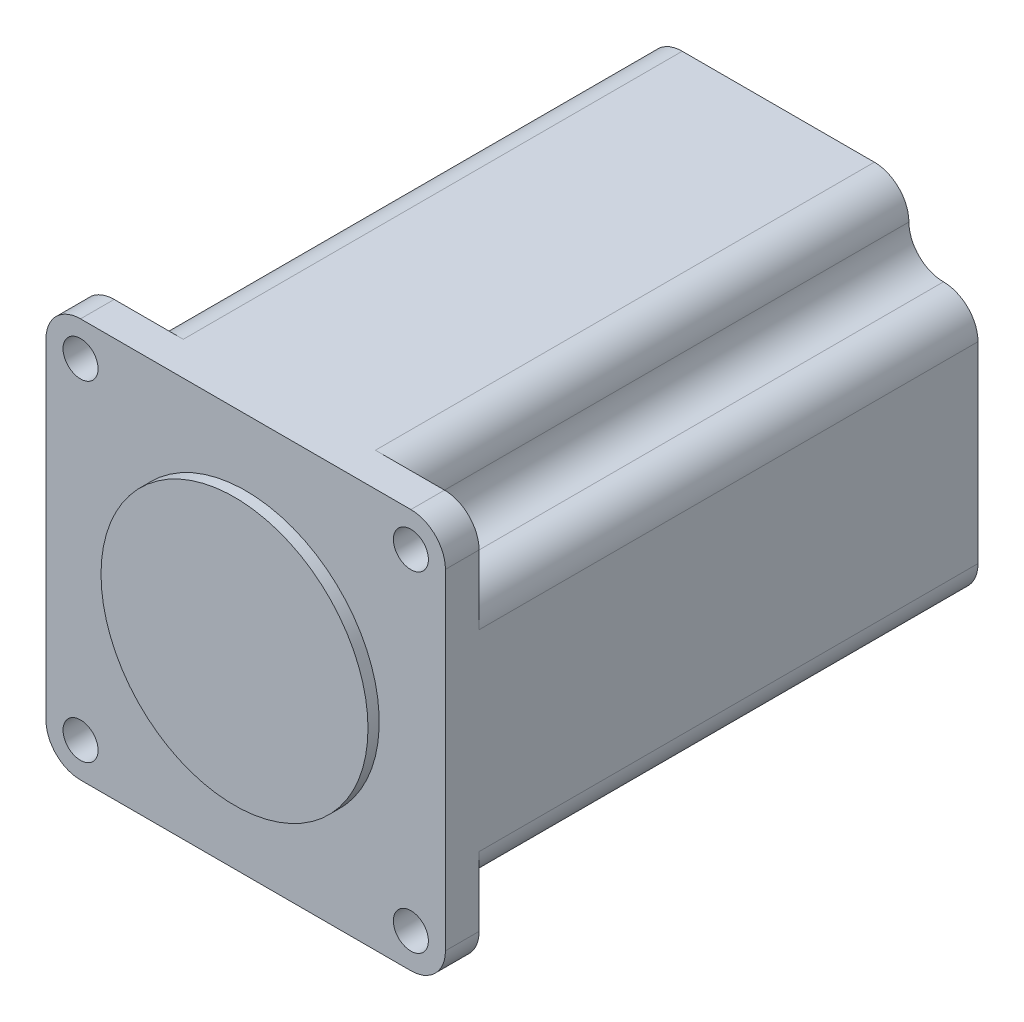
from build123d import *

# Parameters (mm, degrees)
SKETCH1_W           = 57
SKETCH1_H           = 57
BOSS_EXTRUDE1_DEPTH = 76
SKETCH3_R           = 2.5
CUT_EXTRUDE1_DEPTH  = 77
CUT_EXTRUDE2_DEPTH  = 77
SKETCH5_OUTSIDE_W   = 81.158
SKETCH5_OUTSIDE_H   = 81.158
CUT_EXTRUDE3_DEPTH  = 71.2
SKETCH6_R           = 19.05
BOSS_EXTRUDE2_DEPTH = 1.6


with BuildPart() as part:
    # Sketch1 → Boss-Extrude1 (new body)
    with BuildSketch(Plane.XY):
        Rectangle(SKETCH1_W, SKETCH1_H)
    extrude(amount=-BOSS_EXTRUDE1_DEPTH)

    # Sketch3 → Cut-Extrude1 (cut, through all)
    with BuildSketch(Plane(origin=(0, 0, -76), x_dir=(-1, 0, 0), z_dir=(0, 0, -1))):
        with Locations((-23.57, 23.57)):
            Circle(SKETCH3_R)
        with Locations((-23.57, -23.57)):
            Circle(SKETCH3_R)
        with Locations((23.57, 23.57)):
            Circle(SKETCH3_R)
        with Locations((23.57, -23.57)):
            Circle(SKETCH3_R)
    extrude(amount=-CUT_EXTRUDE1_DEPTH, mode=Mode.SUBTRACT)

    # Sketch4 → Cut-Extrude2 (cut, through all)
    with BuildSketch(Plane(origin=(0, 0, -76), x_dir=(-1, 0, 0), z_dir=(0, 0, -1))):
        with BuildLine():
            Line((-28.5, 23.57), (-28.5, 28.5))
            Line((-28.5, 28.5), (-23.57, 28.5))
            ThreePointArc((-23.57, 28.5), (-27.056036431, 27.056036431), (-28.5, 23.57))
        make_face()
        with BuildLine():
            Line((23.57, 28.5), (28.5, 28.5))
            Line((28.5, 28.5), (28.5, 23.57))
            ThreePointArc((28.5, 23.57), (27.056036431, 27.056036431), (23.57, 28.5))
        make_face()
        with BuildLine():
            Line((-28.5, -23.57), (-28.5, -28.5))
            Line((-28.5, -28.5), (-23.57, -28.5))
            ThreePointArc((-23.57, -28.5), (-27.056036431, -27.056036431), (-28.5, -23.57))
        make_face()
        with BuildLine():
            Line((23.57, -28.5), (28.5, -28.5))
            Line((28.5, -28.5), (28.5, -23.57))
            ThreePointArc((28.5, -23.57), (27.056036431, -27.056036431), (23.57, -28.5))
        make_face()
    extrude(amount=-CUT_EXTRUDE2_DEPTH, mode=Mode.SUBTRACT)

    # Sketch5 outside → Cut-Extrude3 (cut)
    with BuildSketch(Plane(origin=(0, 0, -76), x_dir=(-1, 0, 0), z_dir=(0, 0, -1))):
        Rectangle(SKETCH5_OUTSIDE_W, SKETCH5_OUTSIDE_H)
        with BuildLine():
            Line((-28.5, 13.71), (-28.5, -13.71))
            ThreePointArc((-28.5, -13.71), (-27.056036431, -17.196036431), (-23.57, -18.64))
            ThreePointArc((-23.57, -18.64), (-20.083963569, -20.083963569), (-18.64, -23.57))
            ThreePointArc((-18.64, -23.57), (-17.196036431, -27.056036431), (-13.71, -28.5))
            Line((-13.71, -28.5), (13.71, -28.5))
            ThreePointArc((13.71, -28.5), (17.196036431, -27.056036431), (18.64, -23.57))
            ThreePointArc((18.64, -23.57), (20.083963569, -20.083963569), (23.57, -18.64))
            ThreePointArc((23.57, -18.64), (27.056036431, -17.196036431), (28.5, -13.71))
            Line((28.5, -13.71), (28.5, 13.71))
            ThreePointArc((28.5, 13.71), (27.056036431, 17.196036431), (23.57, 18.64))
            ThreePointArc((23.57, 18.64), (20.083963569, 20.083963569), (18.64, 23.57))
            ThreePointArc((18.64, 23.57), (17.196036431, 27.056036431), (13.71, 28.5))
            Line((13.71, 28.5), (-13.71, 28.5))
            ThreePointArc((-13.71, 28.5), (-17.196036431, 27.056036431), (-18.64, 23.57))
            ThreePointArc((-18.64, 23.57), (-20.083963569, 20.083963569), (-23.57, 18.64))
            ThreePointArc((-23.57, 18.64), (-27.056036431, 17.196036431), (-28.5, 13.71))
        make_face(mode=Mode.SUBTRACT)
    extrude(amount=-CUT_EXTRUDE3_DEPTH, mode=Mode.SUBTRACT)

    # Sketch6 → Boss-Extrude2 (add)
    with BuildSketch(Plane.XY):
        Circle(SKETCH6_R)
    extrude(amount=BOSS_EXTRUDE2_DEPTH)


solid = part.part
